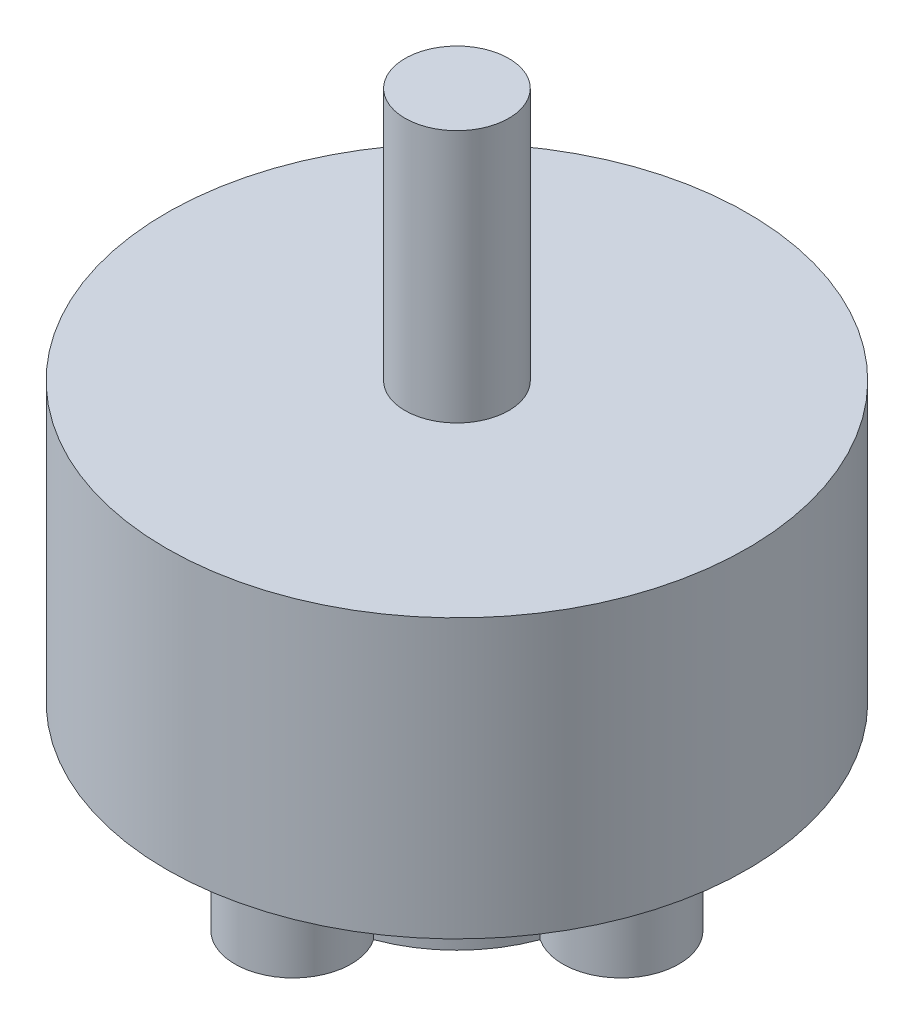
from build123d import *

# Parameters (mm, degrees)
SKETCH1_R           = 14
BOSS_EXTRUDE1_DEPTH = 13.4
SKETCH2_R           = 2.5
BOSS_EXTRUDE2_DEPTH = 12.2
SKETCH3_R           = 6.75
BOSS_EXTRUDE3_DEPTH = 5.6


with BuildPart() as part:
    # Sketch1 → Boss-Extrude1 (new body)
    with BuildSketch(Plane(origin=(0, 0, 0), x_dir=(1, 0, 0), z_dir=(0, 1, 0))):
        Circle(SKETCH1_R)
    extrude(amount=BOSS_EXTRUDE1_DEPTH)

    # Sketch2 → Boss-Extrude2 (add)
    with BuildSketch(Plane(origin=(0, 13.4, 0), x_dir=(1, 0, 0), z_dir=(0, 1, 0))):
        Circle(SKETCH2_R)
    extrude(amount=BOSS_EXTRUDE2_DEPTH)

    # Sketch3 → Boss-Extrude3 (add)
    with BuildSketch(Plane.XZ):
        Circle(SKETCH3_R)
        with BuildLine():
            ThreePointArc((-6.734810127, 0.452584311), (-6.602756441, 1.402179513), (-6.3375, 2.323487411))
            ThreePointArc((-6.3375, 2.323487411), (-10.7, 0), (-6.3375, -2.323487411))
            ThreePointArc((-6.3375, -2.323487411), (-6.602756441, -1.402179513), (-6.734810127, -0.452584311))
            ThreePointArc((-6.734810127, -0.452584311), (-9.15, 0), (-6.734810127, 0.452584311))
        make_face()
        with BuildLine():
            ThreePointArc((0.452584311, 6.734810127), (1.402179513, 6.602756441), (2.323487411, 6.3375))
            ThreePointArc((2.323487411, 6.3375), (0, 10.7), (-2.323487411, 6.3375))
            ThreePointArc((-2.323487411, 6.3375), (-1.402179513, 6.602756441), (-0.452584311, 6.734810127))
            ThreePointArc((-0.452584311, 6.734810127), (0, 9.15), (0.452584311, 6.734810127))
        make_face()
        with BuildLine():
            ThreePointArc((-2.323487411, -6.3375), (0, -10.7), (2.323487411, -6.3375))
            ThreePointArc((2.323487411, -6.3375), (1.402179513, -6.602756441), (0.452584311, -6.734810127))
            ThreePointArc((0.452584311, -6.734810127), (0, -9.15), (-0.452584311, -6.734810127))
            ThreePointArc((-0.452584311, -6.734810127), (-1.402179513, -6.602756441), (-2.323487411, -6.3375))
        make_face()
        with BuildLine():
            ThreePointArc((6.3375, 2.323487411), (6.602756441, 1.402179513), (6.734810127, 0.452584311))
            ThreePointArc((6.734810127, 0.452584311), (9.15, 0), (6.734810127, -0.452584311))
            ThreePointArc((6.734810127, -0.452584311), (6.602756441, -1.402179513), (6.3375, -2.323487411))
            ThreePointArc((6.3375, -2.323487411), (10.7, 0), (6.3375, 2.323487411))
        make_face()
    extrude(amount=BOSS_EXTRUDE3_DEPTH)


solid = part.part
